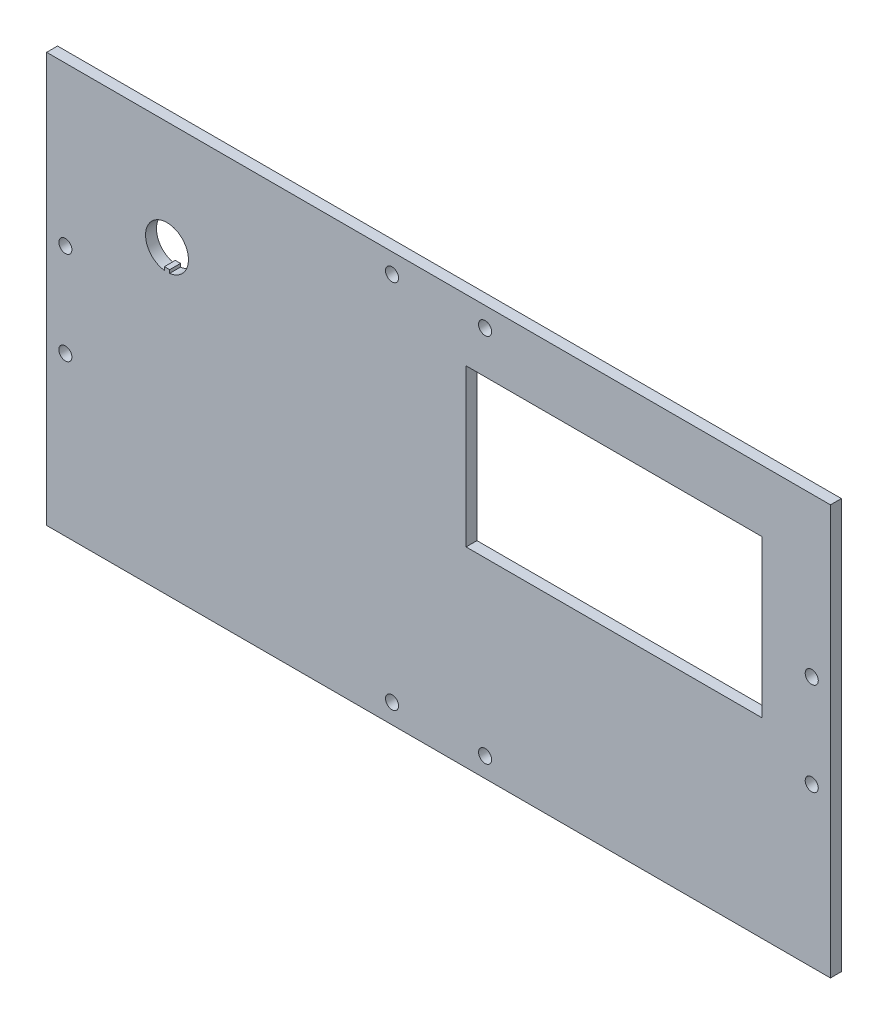
from build123d import *

# Parameters (mm, degrees)
SKETCH1_W           = 228.346
SKETCH1_H           = 119.38
SKETCH1_R           = 1.905
SKETCH1_W_2         = 86.15
SKETCH1_H_2         = 45.7
BOSS_EXTRUDE1_DEPTH = 3.175


with BuildPart() as part:
    # Sketch1 → Boss-Extrude1 (new body)
    with BuildSketch(Plane.XY):
        Rectangle(SKETCH1_W, SKETCH1_H)
        with Locations((-13.5509, -53.975)):
            Circle(SKETCH1_R, mode=Mode.SUBTRACT)
        with Locations((-108.72089, -13.5509)):
            Circle(SKETCH1_R, mode=Mode.SUBTRACT)
        with Locations((13.5509, -53.975)):
            Circle(SKETCH1_R, mode=Mode.SUBTRACT)
        with Locations((108.72089, -13.5509)):
            Circle(SKETCH1_R, mode=Mode.SUBTRACT)
        with Locations((-108.72089, 13.5509)):
            Circle(SKETCH1_R, mode=Mode.SUBTRACT)
        with BuildLine():
            Line((-78.34900876, 21.812054109), (-78.34900876, 22.756016646))
            Line((-78.34900876, 22.756016646), (-79.87300876, 22.756016646))
            Line((-79.87300876, 22.756016646), (-79.87300876, 21.812054109))
            ThreePointArc((-79.87300876, 21.812054109), (-79.11100876, 34.262216646), (-78.34900876, 21.812054109))
        make_face(mode=Mode.SUBTRACT)
        with Locations((-13.5509, 53.975)):
            Circle(SKETCH1_R, mode=Mode.SUBTRACT)
        with Locations((51.098, 18.84)):
            Rectangle(SKETCH1_W_2, SKETCH1_H_2, mode=Mode.SUBTRACT)
        with Locations((108.72089, 13.5509)):
            Circle(SKETCH1_R, mode=Mode.SUBTRACT)
        with Locations((13.5509, 53.975)):
            Circle(SKETCH1_R, mode=Mode.SUBTRACT)
    extrude(amount=BOSS_EXTRUDE1_DEPTH)


solid = part.part
